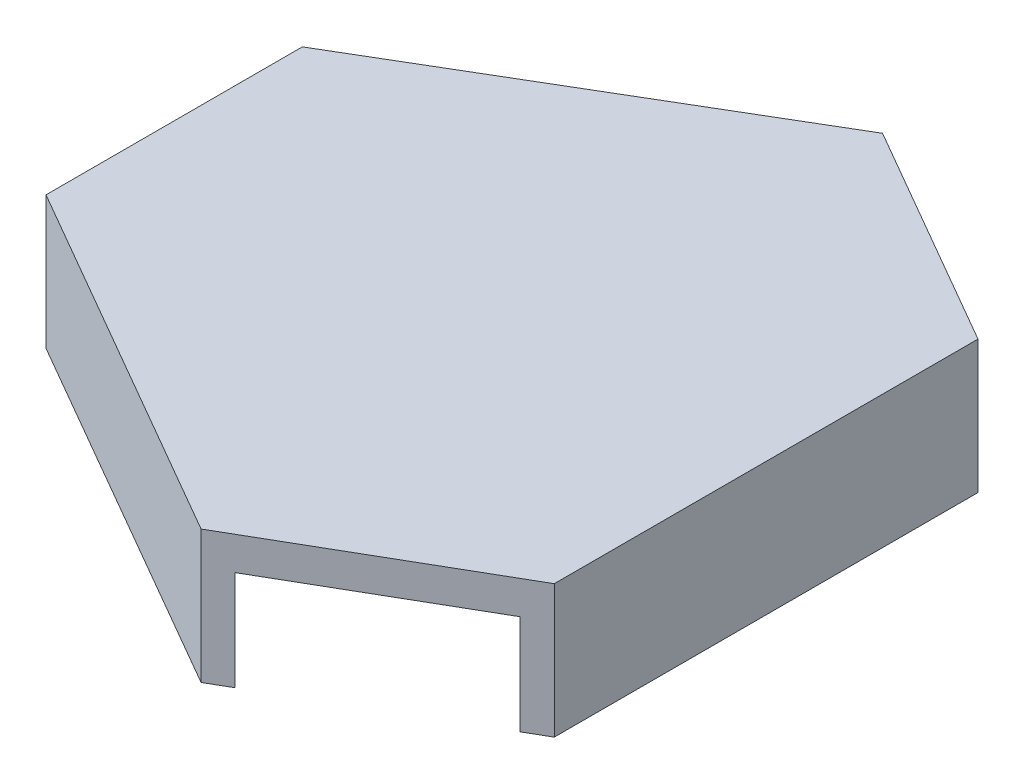
from build123d import *

# Parameters (mm, degrees)
BOSS_EXTRUDE2_DEPTH = 1
BOSS_EXTRUDE3_DEPTH = 3


with BuildPart() as part:
    # Sketch3 → Boss-Extrude2 (new body)
    with BuildSketch(Plane(origin=(0, 0, 0), x_dir=(1, 0, 0), z_dir=(0, 1, 0))):
        Polygon((-9.140125584, 3.822331346), (1.841778899, 10.300006386), (8.641571626, 6.373357215), (8.640464915, -6.376642737), (1.901698314, -10.266239118), (-9.140125584, -3.891239118), align=None)
    extrude(amount=BOSS_EXTRUDE2_DEPTH)

    # Sketch5 → Boss-Extrude3 (add)
    with BuildSketch(Plane.XZ):
        Polygon((-9.140125584, 3.891239118), (1.901698314, 10.266239118), (2.551217367, 9.89133862), (-9.140125584, 3.14133862), align=None)
        Polygon((-9.140125584, -3.822331346), (-9.140125584, -3.06825184), (2.48777328, -9.926966588), (1.841778899, -10.300006386), align=None)
        Polygon((8.640464915, 6.376642737), (8.641571626, -6.373357215), (7.99206405, -6.748425762), (7.990892239, 6.751574187), align=None)
    extrude(amount=BOSS_EXTRUDE3_DEPTH)


solid = part.part
